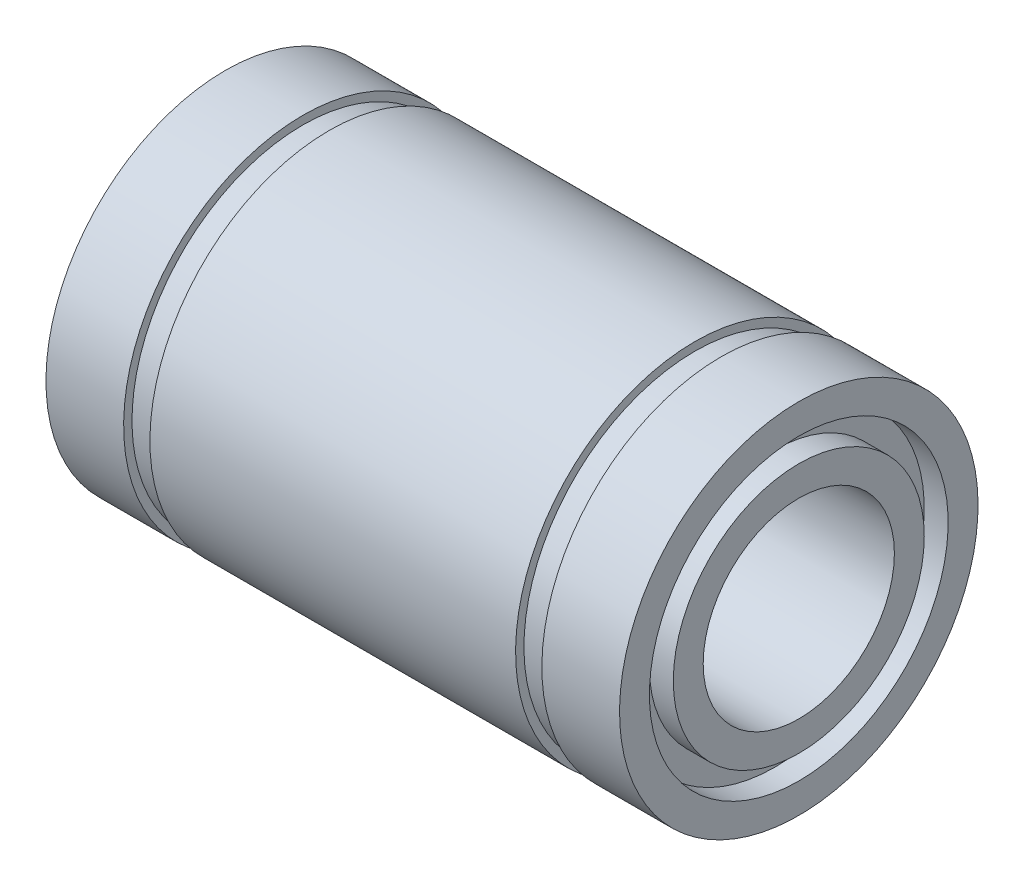
from build123d import *


with BuildPart() as part:
    # Esboço1 → Revolução1 (revolve)
    with BuildSketch(Plane.XY):
        Polygon((-12, 7.5), (-8.75, 7.5), (-8.75, 7.15), (-7.65, 7.15), (-7.65, 7.5), (7.65, 7.5), (7.65, 7.15), (8.75, 7.15), (8.75, 7.5), (12, 7.5), (12, 6.25), (11, 6.25), (11, 5.25), (12, 5.25), (12, 4), (-12, 4), (-12, 5.25), (-11, 5.25), (-11, 6.25), (-12, 6.25), align=None)
    revolve(axis=Axis((0, 0, 0), (-1, 0, 0)))


solid = part.part
